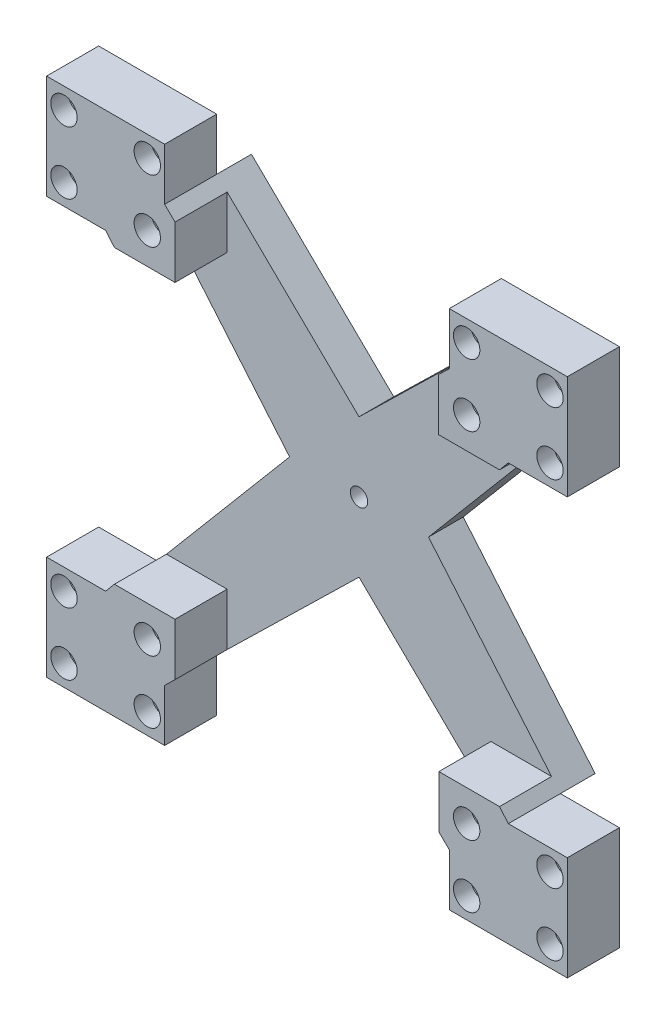
from build123d import *

# Parameters (mm, degrees)
SKETCH1_W           = 150
SKETCH1_H           = 150
BOSS_EXTRUDE1_DEPTH = 15
CUT_EXTRUDE1_DEPTH  = 15
BOSS_EXTRUDE2_DEPTH = 25
CUT_EXTRUDE2_DEPTH  = 15
SKETCH5_R           = 2.5
CUT_EXTRUDE3_DEPTH  = 15
SKETCH7_R           = 2.5
CUT_EXTRUDE4_DEPTH  = 15
SKETCH8_R           = 3.8
CUT_EXTRUDE5_DEPTH  = 5
SKETCH10_R          = 2.5
CUT_EXTRUDE6_DEPTH  = 26
SKETCH11_R          = 3.8
CUT_EXTRUDE7_DEPTH  = 5
SKETCH12_R          = 2.5
CUT_EXTRUDE8_DEPTH  = 26
SKETCH13_R          = 3.8
CUT_EXTRUDE9_DEPTH  = 5
SKETCH14_R          = 2.5
CUT_EXTRUDE10_DEPTH = 26
SKETCH15_R          = 3.8
CUT_EXTRUDE11_DEPTH = 5


with BuildPart() as part:
    # Sketch1 → Boss-Extrude1 (new body)
    with BuildSketch(Plane.XY):
        Rectangle(SKETCH1_W, SKETCH1_H)
    extrude(amount=BOSS_EXTRUDE1_DEPTH)

    # Sketch2 → Cut-Extrude1 (cut)
    with BuildSketch(Plane.XY.offset(15)):
        Polygon((-41, 75), (-41, 60), (0, 20), (41, 60), (41, 75), align=None)
        Polygon((-20, 0), (-58, 45), (-75, 45), (-75, -45), (-58, -45), align=None)
        Polygon((58, 45), (20, 0), (58, -45), (75, -45), (75, 45), align=None)
        Polygon((41, -60), (0, -20), (-41, -60), (-41, -75), (41, -75), align=None)
    extrude(amount=-CUT_EXTRUDE1_DEPTH, mode=Mode.SUBTRACT)

    # Sketch3 → Boss-Extrude2 (add)
    with BuildSketch(Plane.XY.offset(15)):
        Polygon((-41, 45.069428085), (-58, 45.069428085), (-20, 0), (-58, -45), (-41, -45), (-41, -60), (0, -20), (41, -60), (41, -45), (58, -45), (20, 0), (58, 45), (41, 45), (41, 60), (0, 20), (-41, 60), align=None)
    extrude(amount=-BOSS_EXTRUDE2_DEPTH)

    # Sketch4 → Cut-Extrude2 (cut)
    with BuildSketch(Plane.XY.offset(15)):
        Polygon((-38, -42), (-38, -57.073170732), (0, -20), (38, -57.073170732), (38, -42), (55.466666667, -42), (20, 0), (55.466666667, 42), (37.925, 42), (37.925, 57), (0, 20), (-37.220661316, 56.312840308), (-37.426275475, 56.513439488), (-38, 57.073170732), (-38, 42), (-55.466666667, 42), (-20, 0), (-55.466666667, -42), align=None)
    extrude(amount=-CUT_EXTRUDE2_DEPTH, mode=Mode.SUBTRACT)

    # Sketch5 → Cut-Extrude3 (cut)
    with BuildSketch(Plane.XY):
        Circle(SKETCH5_R)
    extrude(amount=-CUT_EXTRUDE3_DEPTH, mode=Mode.SUBTRACT)

    # Sketch7 → Cut-Extrude4 (cut)
    with BuildSketch(Plane.XY.offset(15)):
        with Locations((70, -51)):
            Circle(SKETCH7_R)
        with Locations((46, -51)):
            Circle(SKETCH7_R)
        with Locations((46, -69)):
            Circle(SKETCH7_R)
        with Locations((70, -69)):
            Circle(SKETCH7_R)
    extrude(amount=-CUT_EXTRUDE4_DEPTH, mode=Mode.SUBTRACT)

    # Sketch8 → Cut-Extrude5 (cut)
    with BuildSketch(Plane.XY.offset(15)):
        with Locations((46, -51)):
            Circle(SKETCH8_R)
        with Locations((70, -51)):
            Circle(SKETCH8_R)
        with Locations((70, -69)):
            Circle(SKETCH8_R)
        with Locations((46, -69)):
            Circle(SKETCH8_R)
    extrude(amount=-CUT_EXTRUDE5_DEPTH, mode=Mode.SUBTRACT)

    # Sketch10 → Cut-Extrude6 (cut, through all)
    with BuildSketch(Plane.XY.offset(15)):
        with Locations((-46, -69)):
            Circle(SKETCH10_R)
        with Locations((-46, -51)):
            Circle(SKETCH10_R)
        with Locations((-70, -51)):
            Circle(SKETCH10_R)
        with Locations((-70, -69)):
            Circle(SKETCH10_R)
    extrude(amount=-CUT_EXTRUDE6_DEPTH, mode=Mode.SUBTRACT)

    # Sketch11 → Cut-Extrude7 (cut)
    with BuildSketch(Plane.XY.offset(15)):
        with Locations((-70, -51)):
            Circle(SKETCH11_R)
        with Locations((-46, -51)):
            Circle(SKETCH11_R)
        with Locations((-70, -69)):
            Circle(SKETCH11_R)
        with Locations((-46, -69)):
            Circle(SKETCH11_R)
    extrude(amount=-CUT_EXTRUDE7_DEPTH, mode=Mode.SUBTRACT)

    # Sketch12 → Cut-Extrude8 (cut, through all)
    with BuildSketch(Plane.XY.offset(15)):
        with Locations((46, 69)):
            Circle(SKETCH12_R)
        with Locations((70, 69)):
            Circle(SKETCH12_R)
        with Locations((70, 51)):
            Circle(SKETCH12_R)
        with Locations((46, 51)):
            Circle(SKETCH12_R)
    extrude(amount=-CUT_EXTRUDE8_DEPTH, mode=Mode.SUBTRACT)

    # Sketch13 → Cut-Extrude9 (cut)
    with BuildSketch(Plane.XY.offset(15)):
        with Locations((70, 69)):
            Circle(SKETCH13_R)
        with Locations((46, 69)):
            Circle(SKETCH13_R)
        with Locations((46, 51)):
            Circle(SKETCH13_R)
        with Locations((70, 51)):
            Circle(SKETCH13_R)
    extrude(amount=-CUT_EXTRUDE9_DEPTH, mode=Mode.SUBTRACT)

    # Sketch14 → Cut-Extrude10 (cut, through all)
    with BuildSketch(Plane.XY.offset(15)):
        with Locations((-70, 69)):
            Circle(SKETCH14_R)
        with Locations((-46, 69)):
            Circle(SKETCH14_R)
        with Locations((-46, 51)):
            Circle(SKETCH14_R)
        with Locations((-70, 51)):
            Circle(SKETCH14_R)
    extrude(amount=-CUT_EXTRUDE10_DEPTH, mode=Mode.SUBTRACT)

    # Sketch15 → Cut-Extrude11 (cut)
    with BuildSketch(Plane.XY.offset(15)):
        with Locations((-70, 69)):
            Circle(SKETCH15_R)
        with Locations((-46, 69)):
            Circle(SKETCH15_R)
        with Locations((-46, 51)):
            Circle(SKETCH15_R)
        with Locations((-70, 51)):
            Circle(SKETCH15_R)
    extrude(amount=-CUT_EXTRUDE11_DEPTH, mode=Mode.SUBTRACT)


solid = part.part
